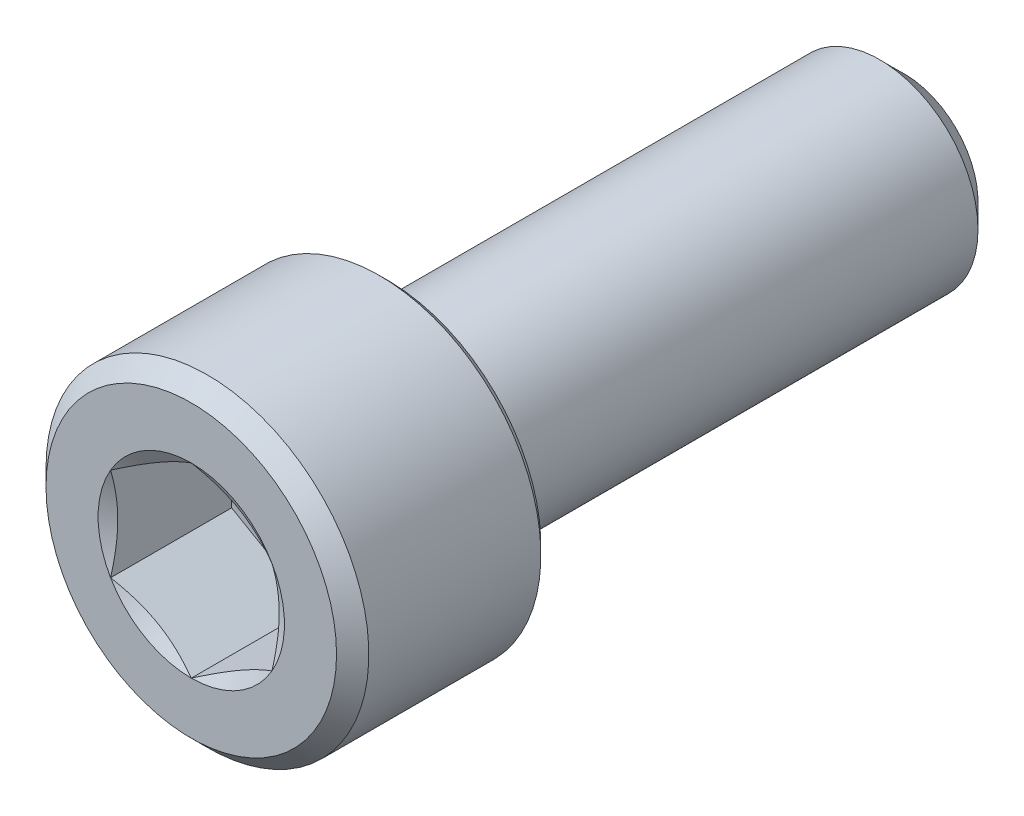
from build123d import *

# Parameters (mm, degrees)
CUT_EXTRUDE1_DEPTH = 2.9765625
CHAMFER1_SIZE      = 0.396875
CHAMFER2_SIZE      = 0.1984375


with BuildPart() as part:
    # Sketch2 → Revolve1 (revolve)
    with BuildSketch(Plane(origin=(0, 0, 0), x_dir=(0, 0, -1), z_dir=(1, 0, 0))):
        Polygon((8.763, 1.8176875), (8.1676875, 2.413), (-3.937, 2.413), (-3.937, 3.96875), (-8.763, 3.96875), (-8.763, 0), (8.763, 0), align=None)
    revolve(axis=Axis((0, 0, -8.763), (0, 0, 1)))

    # Sketch4 → Cut-Extrude1 (cut)
    with BuildSketch(Plane.XY.offset(8.763)):
        Polygon((0, 2.291358881), (-1.984375, 1.14567944), (-1.984375, -1.14567944), (0, -2.291358881), (1.984375, -1.14567944), (1.984375, 1.14567944), align=None)
    extrude(amount=-CUT_EXTRUDE1_DEPTH, mode=Mode.SUBTRACT)

    # Cut-Extrude2 cone 1 section (through the dimple's axis) → Cut-Extrude2 (revolve, cut)
    with BuildSketch(Plane(origin=(0, 0, 8.763), x_dir=(0, -1, 0), z_dir=(1, 0, 0))):
        Polygon((0, 0), (2.291358881, 0), (0, 1.322916667), align=None)
    revolve(axis=Axis((0, 0, 8.763), (0, 0, -1)), mode=Mode.SUBTRACT)

    # Chamfer1
    chamfer1_edges = [part.edges().sort_by_distance(p)[0] for p in [
        (0, -3.96875, 8.763),
    ]]
    chamfer(chamfer1_edges, length=CHAMFER1_SIZE)

    # Chamfer2
    chamfer2_edges = [part.edges().sort_by_distance(p)[0] for p in [
        (0, -3.96875, 3.937),
    ]]
    chamfer(chamfer2_edges, length=CHAMFER2_SIZE)


solid = part.part
